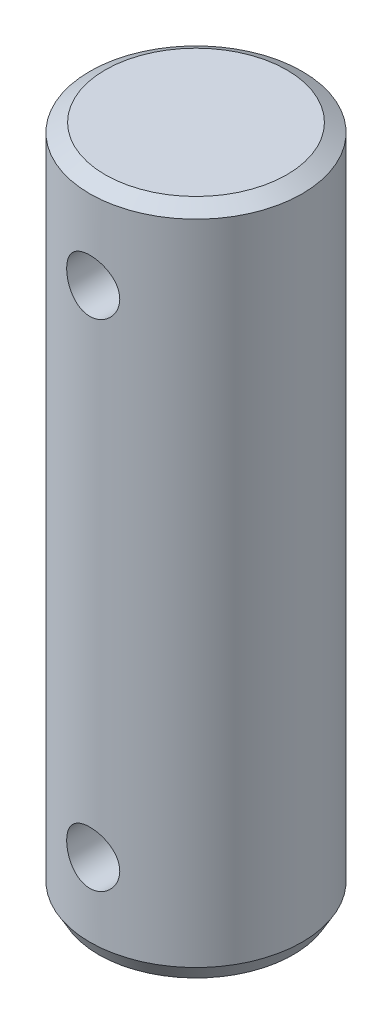
from build123d import *

# Parameters (mm, degrees)
SKETCH1_R               = 6
BOSS_EXTRUDE1_DEPTH     = 19
CHAMFER1_SIZE           = 0.5
CHAMFER1_SIZE2          = 0.866025404
CHAMFER1_PART_2_SIZE    = 0.5
CHAMFER1_PART_2_SIZE2   = 0.866025404
SKETCH2_R               = 1.5
CUT_EXTRUDE1_DEPTH      = 7
CUT_EXTRUDE1_DEPTH_BACK = 7


with BuildPart() as part:
    # Sketch1 → Boss-Extrude1 (new body, symmetric)
    with BuildSketch(Plane(origin=(0, 0, 0), x_dir=(1, 0, 0), z_dir=(0, 1, 0))):
        Circle(SKETCH1_R)
    extrude(amount=BOSS_EXTRUDE1_DEPTH, both=True)

    # Chamfer1
    chamfer1_edges = [part.edges().sort_by_distance(p)[0] for p in [
        (-6, -19, 0),
    ]]
    chamfer1_side = [part.faces().sort_by_distance(p)[0] for p in [
        (0, -19, 0),
    ]]
    chamfer(chamfer1_edges, length=CHAMFER1_SIZE, length2=CHAMFER1_SIZE2, reference=chamfer1_side[0])

    # Chamfer1 part 2
    chamfer1_part_2_edges = [part.edges().sort_by_distance(p)[0] for p in [
        (-6, 19, 0),
    ]]
    chamfer1_part_2_side = [part.faces().sort_by_distance(p)[0] for p in [
        (-6, 0, 0),
    ]]
    chamfer(chamfer1_part_2_edges, length=CHAMFER1_PART_2_SIZE, length2=CHAMFER1_PART_2_SIZE2, reference=chamfer1_part_2_side[0])

    # Sketch2 → Cut-Extrude1 (cut, two sides)
    with BuildSketch(Plane.XY) as cut_extrude1_sk:
        with Locations((0, 14)):
            Circle(SKETCH2_R)
        with Locations((0, -14)):
            Circle(SKETCH2_R)
    extrude(amount=CUT_EXTRUDE1_DEPTH, mode=Mode.SUBTRACT)
    extrude(cut_extrude1_sk.sketch, amount=-CUT_EXTRUDE1_DEPTH_BACK, mode=Mode.SUBTRACT)


solid = part.part
